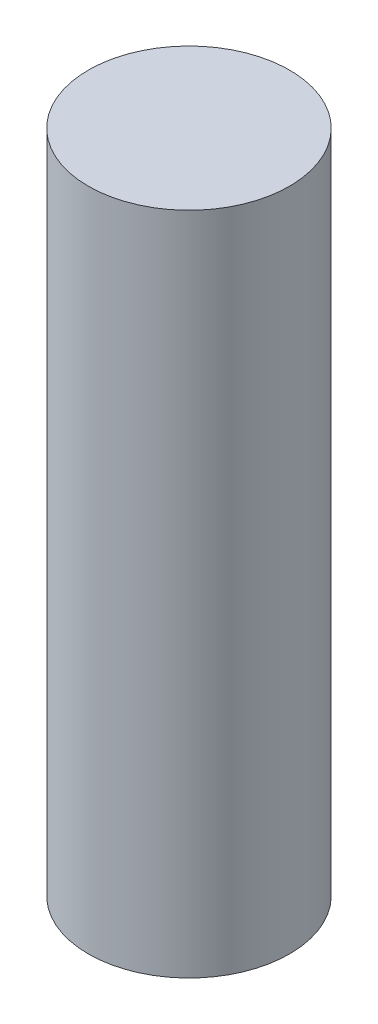
from build123d import *

# Parameters (mm, degrees)
SKETCH1_R           = 18.25625
BOSS_EXTRUDE1_DEPTH = 120.65


with BuildPart() as part:
    # Sketch1 → Boss-Extrude1 (new body)
    with BuildSketch(Plane(origin=(0, 0, 0), x_dir=(1, 0, 0), z_dir=(0, 1, 0))):
        Circle(SKETCH1_R)
    extrude(amount=BOSS_EXTRUDE1_DEPTH)


solid = part.part
